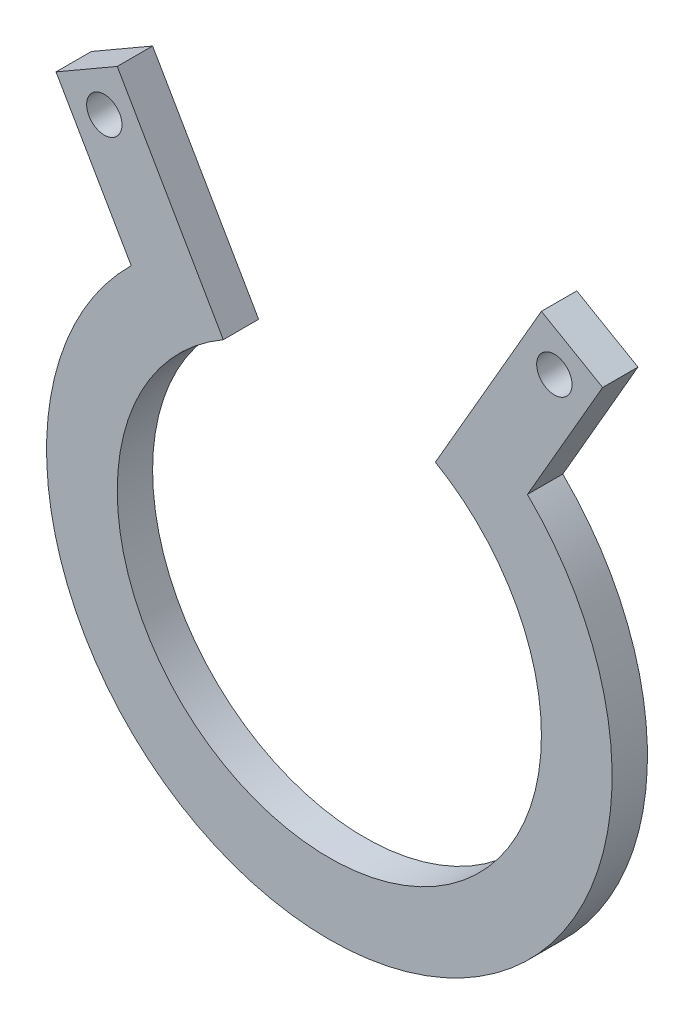
from build123d import *

# Parameters (mm, degrees)
SKETCH2_R           = 25.4
SKETCH2_R_2         = 22.225
SKETCH2_R_3         = 19.05
BOSS_EXTRUDE1_DEPTH = 3.175
SKETCH3_R           = 1.5875
BOSS_EXTRUDE2_DEPTH = 3.175
CUT_EXTRUDE1_DEPTH  = 3.175


with BuildPart() as part:
    # Sketch2 → Boss-Extrude1 (new body)
    with BuildSketch(Plane.XY):
        Circle(SKETCH2_R)
        Circle(SKETCH2_R_2, mode=Mode.SUBTRACT)
        Circle(SKETCH2_R_2)
        Circle(SKETCH2_R_3, mode=Mode.SUBTRACT)
    extrude(amount=BOSS_EXTRUDE1_DEPTH)

    # Sketch3 → Boss-Extrude2 (add)
    with BuildSketch(Plane.XY.offset(3.175)):
        with BuildLine():
            ThreePointArc((-17.795983438, 18.123547486), (-15.370499267, 20.22146761), (-12.7, 21.997045256))
            Line((-12.7, 21.997045256), (-19.05, 32.995567884))
            Line((-19.05, 32.995567884), (-24.549261314, 29.820567884))
            Line((-24.549261314, 29.820567884), (-18.199261314, 18.822045256))
            Line((-18.199261314, 18.822045256), (-17.795983438, 18.123547486))
        make_face()
        with Locations((-20.212130657, 28.658437227)):
            Circle(SKETCH3_R, mode=Mode.SUBTRACT)
        with BuildLine():
            Line((19.05, 32.995567884), (12.7, 21.997045256))
            ThreePointArc((12.7, 21.997045256), (15.370499267, 20.22146761), (17.795983438, 18.123547486))
            Line((17.795983438, 18.123547486), (18.199261314, 18.822045256))
            Line((18.199261314, 18.822045256), (24.549261314, 29.820567884))
            Line((24.549261314, 29.820567884), (19.05, 32.995567884))
        make_face()
        with Locations((20.212130657, 28.658437227)):
            Circle(SKETCH3_R, mode=Mode.SUBTRACT)
    extrude(amount=-BOSS_EXTRUDE2_DEPTH)

    # Sketch5 → Cut-Extrude1 (cut)
    with BuildSketch(Plane.XY.offset(3.175)):
        with BuildLine():
            Line((-12.7, 21.997045256), (0, 0))
            Line((0, 0), (12.7, 21.997045256))
            ThreePointArc((12.7, 21.997045256), (0, 25.4), (-12.7, 21.997045256))
        make_face()
    extrude(amount=-CUT_EXTRUDE1_DEPTH, mode=Mode.SUBTRACT)


solid = part.part
